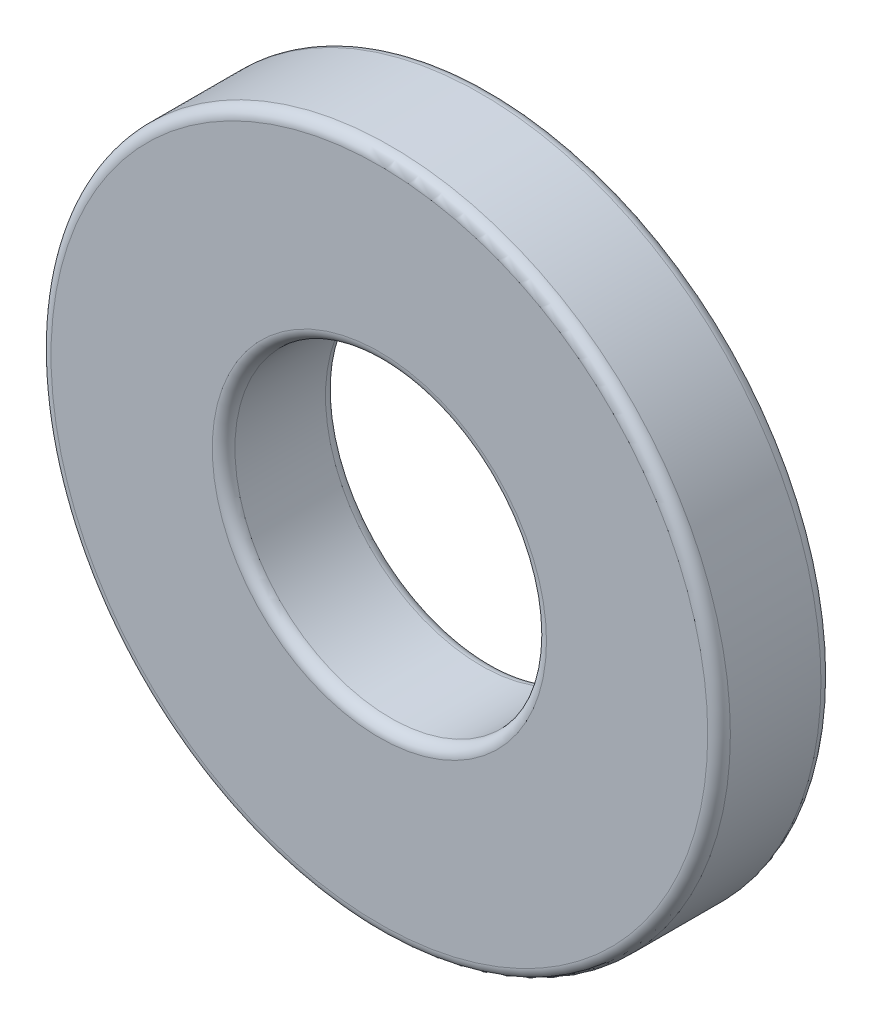
from build123d import *

# Parameters (mm, degrees)
BOSS_EXTRUDE1_START = 1.5875
SKETCH3_R           = 9.525
SKETCH3_R_2         = 4.3688
BOSS_EXTRUDE1_DEPTH = 3.175
FILLET1_R           = 0.3175


with BuildPart() as part:
    # Sketch3 → Boss-Extrude1 (new body)
    with BuildSketch(Plane.XY.offset(BOSS_EXTRUDE1_START)):
        Circle(SKETCH3_R)
        Circle(SKETCH3_R_2, mode=Mode.SUBTRACT)
    extrude(amount=-BOSS_EXTRUDE1_DEPTH)

    # Fillet1
    fillet1_edges = [part.edges().sort_by_distance(p)[0] for p in [
        (-9.525, 0, 1.5875),
        (-9.525, 0, -1.5875),
        (-4.3688, 0, -1.5875),
        (-4.3688, 0, 1.5875),
    ]]
    fillet(fillet1_edges, radius=FILLET1_R)


solid = part.part
